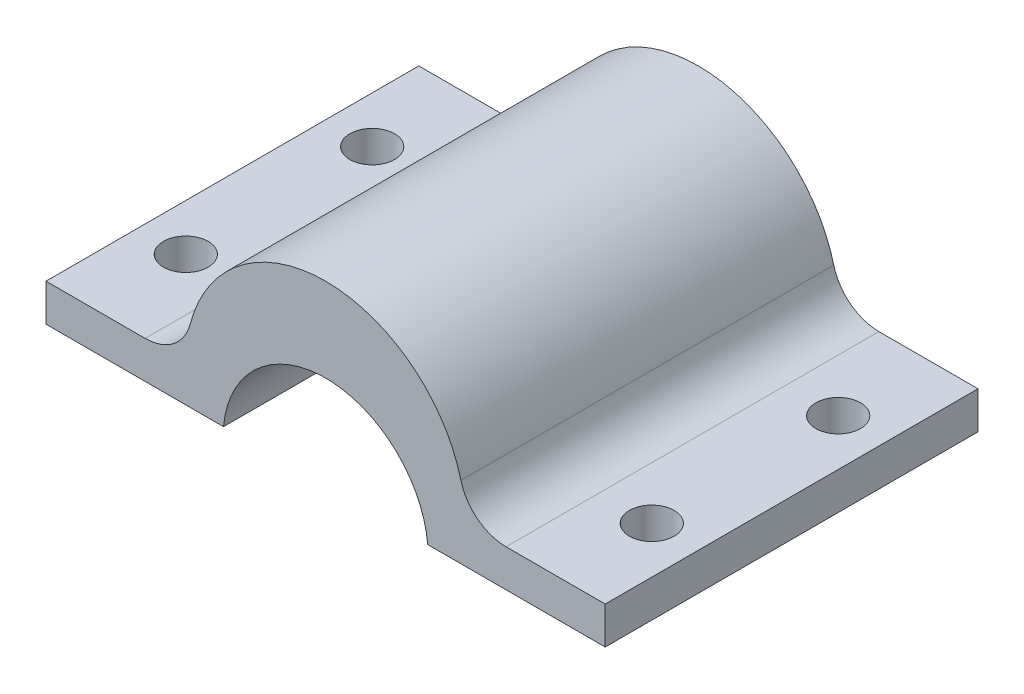
from build123d import *

# Parameters (mm, degrees)
MORS_AMOVIBLE_DEPTH     = 40
ESQUISSE2_R             = 2.4
TROU_FIXATION_DEPTH     = 6
CONG_1_R                = 5
ENL_V_START             = -40
ESQUISSE3_W             = 60
ESQUISSE3_H             = 1
ENL_V_MAT_EXTRU_1_DEPTH = 40


with BuildPart() as part:
    # Esquisse1 → mors_amovible (new body)
    with BuildSketch(Plane.XY):
        with BuildLine():
            Line((60, 0), (60, 5))
            Line((60, 5), (45, 5))
            ThreePointArc((45, 5), (30, 20), (15, 5))
            Line((15, 5), (0, 5))
            Line((0, 5), (0, 0))
            Line((0, 0), (19, 0))
            ThreePointArc((19, 0), (30, 11), (41, 0))
            Line((41, 0), (60, 0))
        make_face()
    extrude(amount=MORS_AMOVIBLE_DEPTH)

    # Esquisse2 → trou_fixation (cut, through all)
    with BuildSketch(Plane(origin=(0, 5, 0), x_dir=(1, 0, 0), z_dir=(0, 1, 0))):
        with Locations((5, -10)):
            Circle(ESQUISSE2_R)
        with Locations((55, -10)):
            Circle(ESQUISSE2_R)
        with Locations((55, -30)):
            Circle(ESQUISSE2_R)
        with Locations((5, -30)):
            Circle(ESQUISSE2_R)
    extrude(amount=-TROU_FIXATION_DEPTH, mode=Mode.SUBTRACT)

    # Congé1
    cong_1_edges = [part.edges().sort_by_distance(p)[0] for p in [
        (15, 5, 20),
        (45, 5, 20),
    ]]
    fillet(cong_1_edges, radius=CONG_1_R)

    # Esquisse3 → Enlèv. mat.-Extru.1 (cut)
    with BuildSketch(Plane(origin=(0, 0, 0), x_dir=(-1, 0, 0), z_dir=(0, 0, -1)).offset(ENL_V_START)):
        with Locations((-30, 0.5)):
            Rectangle(ESQUISSE3_W, ESQUISSE3_H)
    extrude(amount=ENL_V_MAT_EXTRU_1_DEPTH, mode=Mode.SUBTRACT)


solid = part.part
